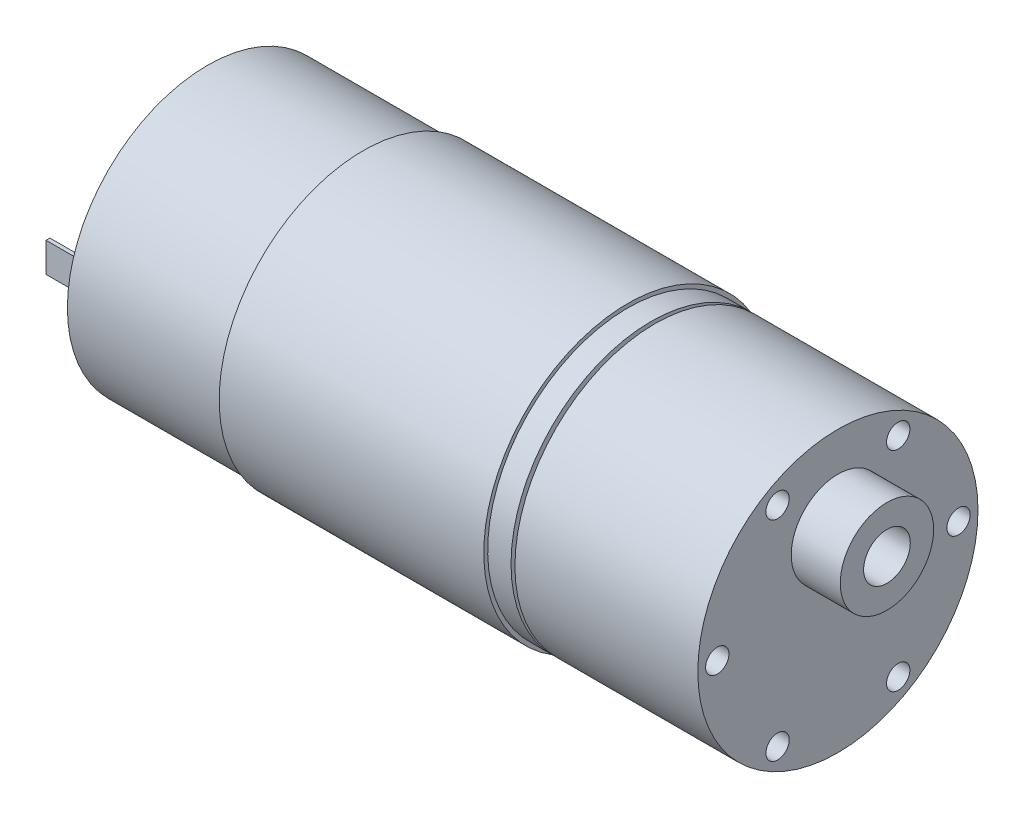
from build123d import *

# Parameters (mm, degrees)
SKETCH1_R           = 18
BOSS_EXTRUDE1_DEPTH = 57
SKETCH2_R           = 17
BOSS_EXTRUDE2_DEPTH = 0.5
SKETCH3_R           = 18
BOSS_EXTRUDE3_DEPTH = 23.5
SKETCH4_R           = 6
SKETCH4_R_2         = 3
BOSS_EXTRUDE4_DEPTH = 6.3
SKETCH6_R           = 1.5
CUT_EXTRUDE1_DEPTH  = 3.5
SKETCH7_R           = 5.5
BOSS_EXTRUDE6_DEPTH = 2
SKETCH8_R           = 1.5
BOSS_EXTRUDE7_DEPTH = 9
SKETCH9_W           = 0.5
SKETCH9_H           = 3.8
BOSS_EXTRUDE8_DEPTH = 7
BOSS_EXTRUDE9_DEPTH = 34


with BuildPart() as part:
    # Sketch1 → Boss-Extrude1 (new body)
    with BuildSketch(Plane(origin=(0, 0, 0), x_dir=(0, 0, -1), z_dir=(1, 0, 0))):
        Circle(SKETCH1_R)
    extrude(amount=BOSS_EXTRUDE1_DEPTH)

    # Sketch2 → Boss-Extrude2 (add)
    with BuildSketch(Plane(origin=(57, 0, 0), x_dir=(0, 0, -1), z_dir=(1, 0, 0))):
        Circle(SKETCH2_R)
    extrude(amount=BOSS_EXTRUDE2_DEPTH)

    # Sketch3 → Boss-Extrude3 (add)
    with BuildSketch(Plane(origin=(57.5, 0, 0), x_dir=(0, 0, -1), z_dir=(1, 0, 0))):
        Circle(SKETCH3_R)
    extrude(amount=BOSS_EXTRUDE3_DEPTH)

    # Sketch4 → Boss-Extrude4 (add)
    with BuildSketch(Plane(origin=(81, 0, 0), x_dir=(0, 0, -1), z_dir=(1, 0, 0))):
        with Locations((0, 7)):
            Circle(SKETCH4_R)
        with Locations((0, 7)):
            Circle(SKETCH4_R_2, mode=Mode.SUBTRACT)
    extrude(amount=BOSS_EXTRUDE4_DEPTH)

    # Sketch6 → Cut-Extrude1 (cut)
    with BuildSketch(Plane(origin=(81, 0, 0), x_dir=(0, 0, -1), z_dir=(1, 0, 0))):
        with Locations((-15.5, 0)):
            Circle(SKETCH6_R)
        with Locations((-7.75, 13.423393759)):
            Circle(SKETCH6_R)
        with Locations((7.75, 13.423393759)):
            Circle(SKETCH6_R)
        with Locations((15.5, 0)):
            Circle(SKETCH6_R)
        with Locations((7.75, -13.423393759)):
            Circle(SKETCH6_R)
        with Locations((-7.75, -13.423393759)):
            Circle(SKETCH6_R)
    extrude(amount=-CUT_EXTRUDE1_DEPTH, mode=Mode.SUBTRACT)

    # Sketch7 → Boss-Extrude6 (add)
    with BuildSketch(Plane.ZY):
        Circle(SKETCH7_R)
    extrude(amount=BOSS_EXTRUDE6_DEPTH)

    # Sketch8 → Boss-Extrude7 (add)
    with BuildSketch(Plane.ZY.offset(2)):
        Circle(SKETCH8_R)
    extrude(amount=BOSS_EXTRUDE7_DEPTH)

    # Sketch9 → Boss-Extrude8 (add)
    with BuildSketch(Plane.ZY):
        with Locations((13.5, 0)):
            Rectangle(SKETCH9_W, SKETCH9_H)
        with Locations((-13.434451739, 0)):
            Rectangle(SKETCH9_W, SKETCH9_H)
    extrude(amount=BOSS_EXTRUDE8_DEPTH)

    # Sketch10 → Boss-Extrude9 (add)
    with BuildSketch(Plane(origin=(54, 0, 0), x_dir=(0, 0, -1), z_dir=(1, 0, 0))):
        with BuildLine():
            Line((2.881280854, -17.767898599), (2.961316433, -18.261451338))
            ThreePointArc((2.961316433, -18.261451338), (0, 18.5), (-2.961316433, -18.261451338))
            Line((-2.961316433, -18.261451338), (-2.881280854, -17.767898599))
            ThreePointArc((-2.881280854, -17.767898599), (0, 18), (2.881280854, -17.767898599))
        make_face()
    extrude(amount=-BOSS_EXTRUDE9_DEPTH)


solid = part.part
